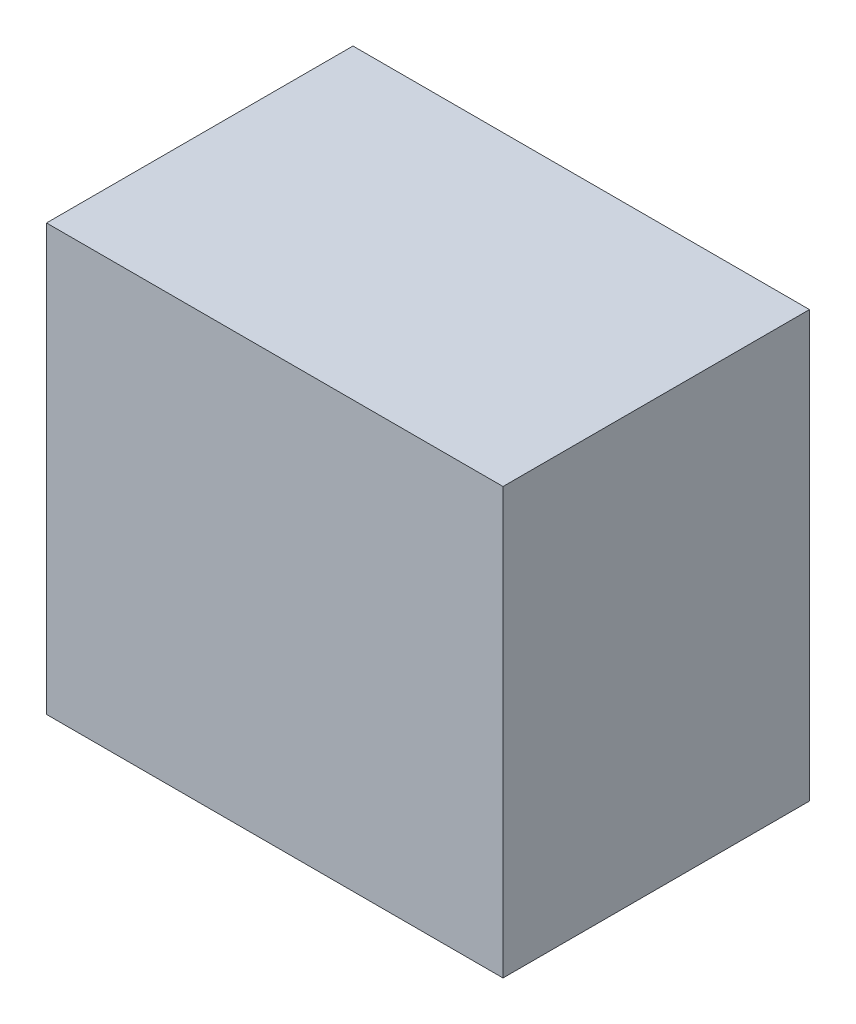
from build123d import *

# Parameters (mm, degrees)
SKETCH1_W           = 42.9
SKETCH1_H           = 40
BOSS_EXTRUDE1_DEPTH = 28.8


with BuildPart() as part:
    # Sketch1 → Boss-Extrude1 (new body)
    with BuildSketch(Plane.XY):
        with Locations((-8.740735879, 2.680786175)):
            Rectangle(SKETCH1_W, SKETCH1_H)
    extrude(amount=BOSS_EXTRUDE1_DEPTH)


solid = part.part
